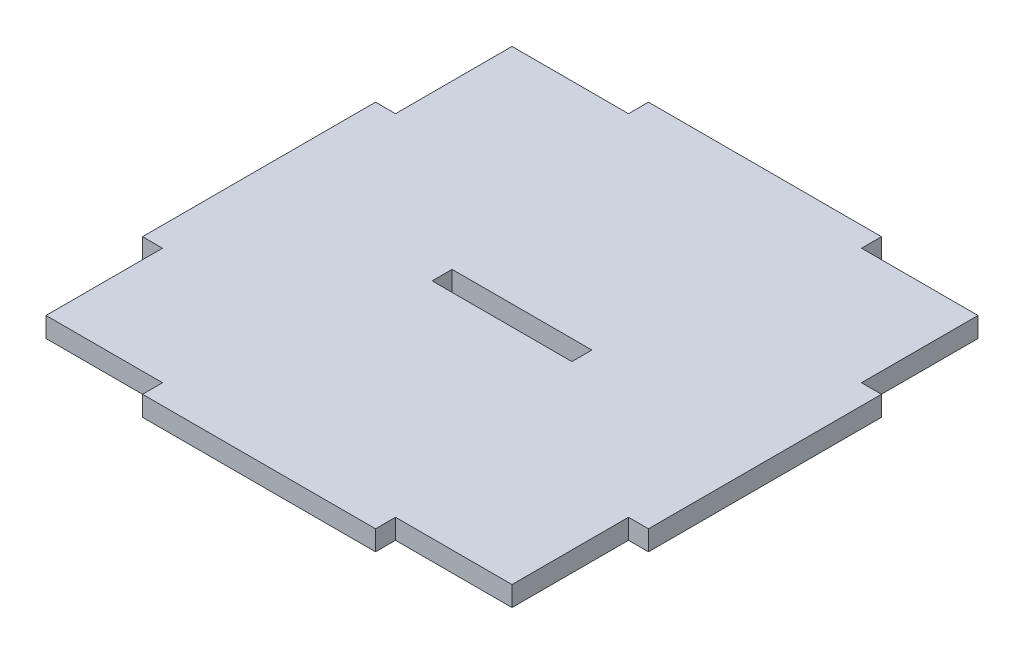
from build123d import *

# Parameters (mm, degrees)
BOSS_EXTRUDE1_DEPTH = 3
SKETCH2_W           = 21
SKETCH2_H           = 3
CUT_EXTRUDE1_DEPTH  = 3


with BuildPart() as part:
    # Sketch1 → Boss-Extrude1 (new body)
    with BuildSketch(Plane(origin=(0, 0, 0), x_dir=(1, 0, 0), z_dir=(0, 1, 0))):
        Polygon((-35, -35), (-17.5, -35), (-17.5, -38), (17.5, -38), (17.5, -35), (35, -35), (35, -17.5), (38, -17.5), (38, 17.5), (35, 17.5), (35, 35), (17.5, 35), (17.5, 38), (-17.5, 38), (-17.5, 35), (-35, 35), (-35, 17.5), (-38, 17.5), (-38, -17.5), (-35, -17.5), align=None)
    extrude(amount=BOSS_EXTRUDE1_DEPTH)

    # Sketch2 → Cut-Extrude1 (cut)
    with BuildSketch(Plane(origin=(0, 3, 0), x_dir=(1, 0, 0), z_dir=(0, 1, 0))):
        Rectangle(SKETCH2_W, SKETCH2_H)
    extrude(amount=-CUT_EXTRUDE1_DEPTH, mode=Mode.SUBTRACT)


solid = part.part
